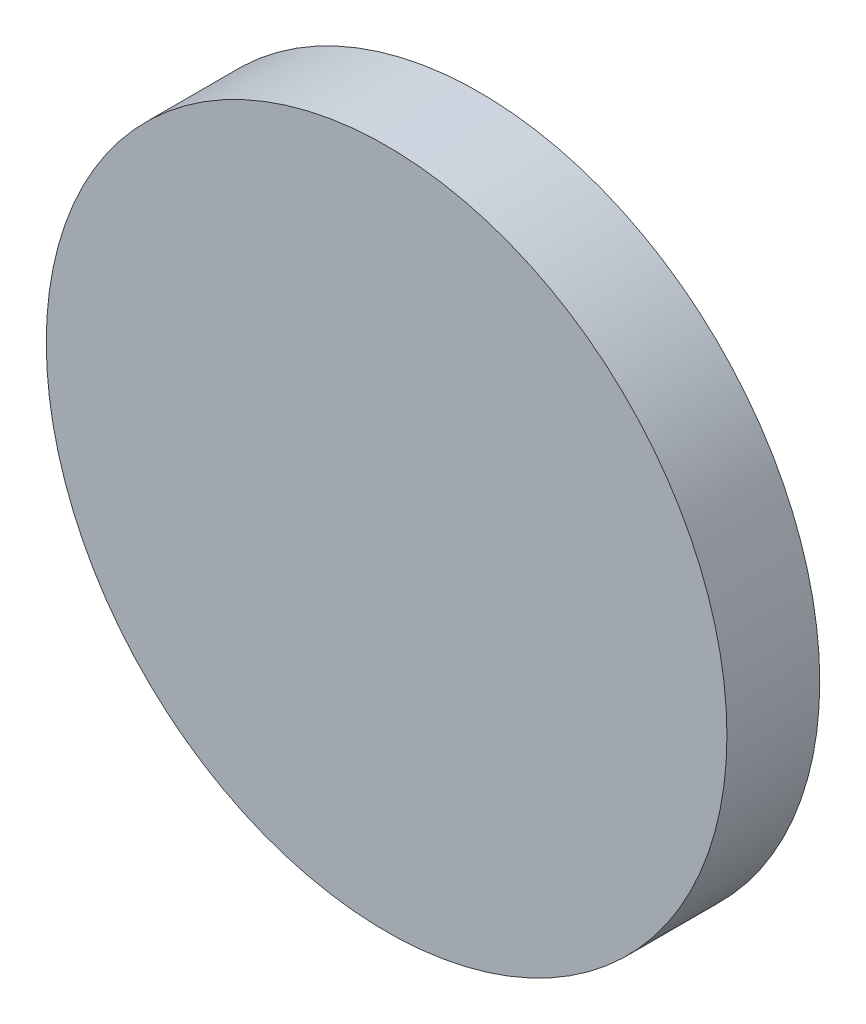
from build123d import *

# Parameters (mm, degrees)
SKETCH1_R           = 9.314219985
BOSS_EXTRUDE1_DEPTH = 2.54


with BuildPart() as part:
    # Sketch1 → Boss-Extrude1 (new body)
    with BuildSketch(Plane.XY):
        Circle(SKETCH1_R)
    extrude(amount=BOSS_EXTRUDE1_DEPTH)


solid = part.part
